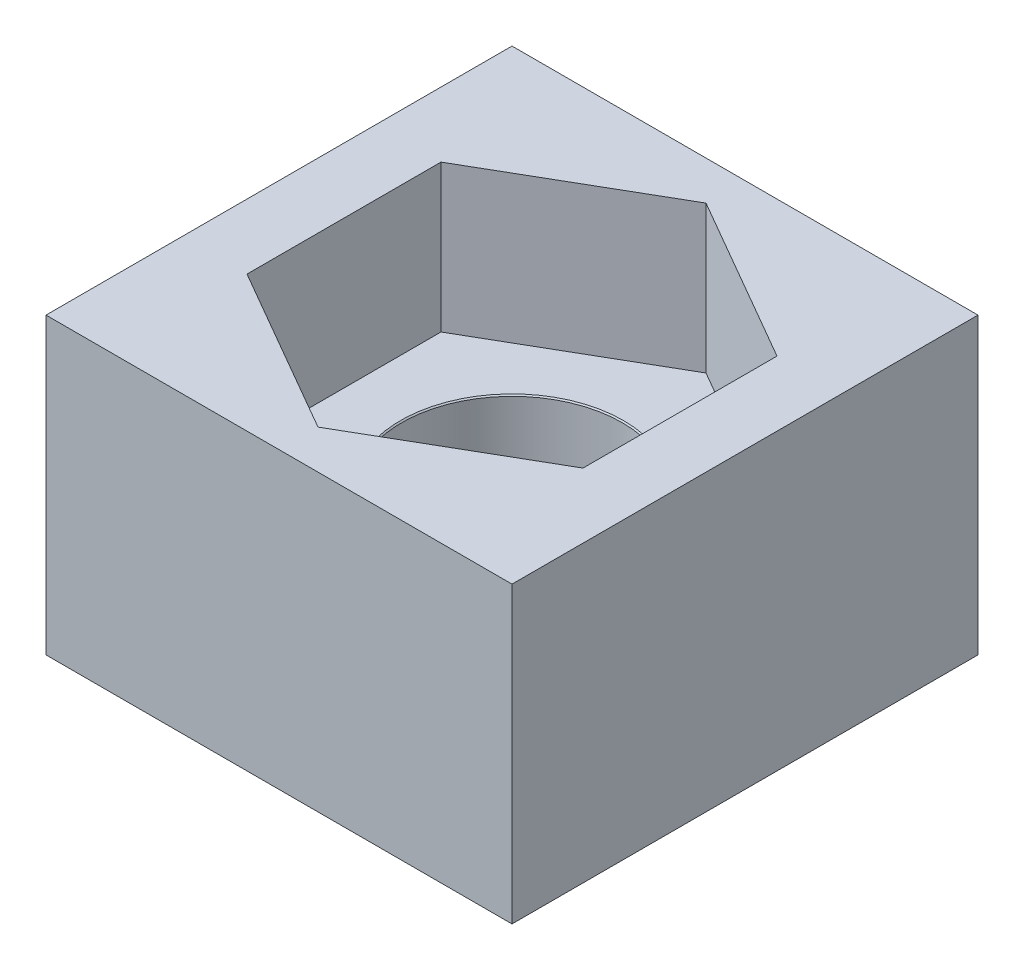
from build123d import *

# Parameters (mm, degrees)
SKETCH1_W                      = 9.5
SKETCH1_H                      = 9.5
BOSS_EXTRUDE1_DEPTH            = 6
CUT_EXTRUDE1_DEPTH             = 3
M4_CLEARANCE_HOLE1_D           = 4.5
M4_CLEARANCE_HOLE1_CSINK_D     = 4.55
M4_CLEARANCE_HOLE1_CSINK_ANGLE = 90


with BuildPart() as part:
    # Sketch1 → Boss-Extrude1 (new body)
    with BuildSketch(Plane(origin=(0, 0, 0), x_dir=(1, 0, 0), z_dir=(0, 1, 0))):
        Rectangle(SKETCH1_W, SKETCH1_H)
    extrude(amount=BOSS_EXTRUDE1_DEPTH)

    # Sketch2 → Cut-Extrude1 (cut)
    with BuildSketch(Plane(origin=(0, 6, 0), x_dir=(1, 0, 0), z_dir=(0, 1, 0))):
        Polygon((0, -3.954849344), (3.425, -1.977424672), (3.425, 1.977424672), (0, 3.954849344), (-3.425, 1.977424672), (-3.425, -1.977424672), align=None)
    extrude(amount=-CUT_EXTRUDE1_DEPTH, mode=Mode.SUBTRACT)

    # M4 Clearance Hole1 (through all)
    with Locations(Plane(origin=(0, 3, 0), x_dir=(1, 0, 0), z_dir=(0, 1, 0))):
        with Locations((0, 0)):
            CounterSinkHole(M4_CLEARANCE_HOLE1_D / 2, M4_CLEARANCE_HOLE1_CSINK_D / 2, counter_sink_angle=M4_CLEARANCE_HOLE1_CSINK_ANGLE)


solid = part.part
